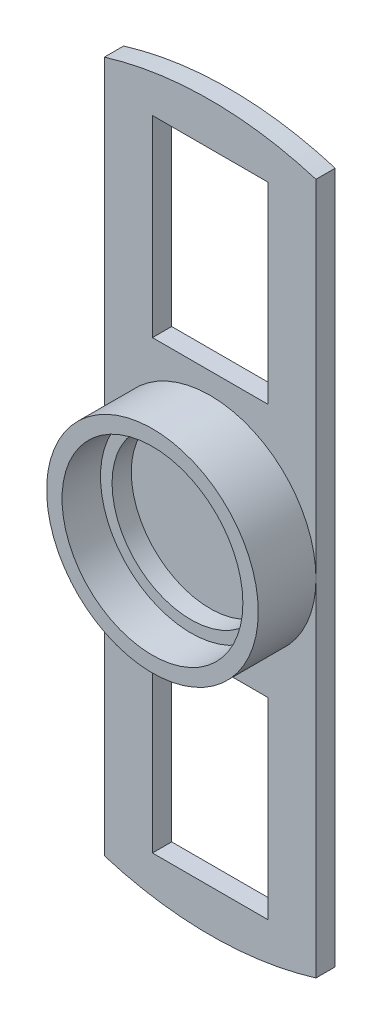
from build123d import *

# Parameters (mm, degrees)
SKETCH1_R           = 27.5
SKETCH1_R_2         = 23.5
BOSS_EXTRUDE1_DEPTH = 10
SKETCH2_R           = 27.5
SKETCH2_R_2         = 20.5
BOSS_EXTRUDE2_DEPTH = 5
BOSS_EXTRUDE3_DEPTH = 5
SKETCH4_W           = 30
SKETCH4_H           = 50
CUT_EXTRUDE1_DEPTH  = 10


with BuildPart() as part:
    # Sketch1 → Boss-Extrude1 (new body)
    with BuildSketch(Plane.XY):
        Circle(SKETCH1_R)
        Circle(SKETCH1_R_2, mode=Mode.SUBTRACT)
    extrude(amount=BOSS_EXTRUDE1_DEPTH)

    # Sketch2 → Boss-Extrude2 (add)
    with BuildSketch(Plane(origin=(0, 0, 0), x_dir=(-1, 0, 0), z_dir=(0, 0, -1))):
        Circle(SKETCH2_R)
        Circle(SKETCH2_R_2, mode=Mode.SUBTRACT)
    extrude(amount=BOSS_EXTRUDE2_DEPTH)

    # Sketch3 → Boss-Extrude3 (add)
    with BuildSketch(Plane(origin=(0, 0, -5), x_dir=(-1, 0, 0), z_dir=(0, 0, -1))):
        with BuildLine():
            Line((-27.5, 89.887429599), (-27.5, -89.887429599))
            ThreePointArc((-27.5, -89.887429599), (0, -94), (27.5, -89.887429599))
            Line((27.5, -89.887429599), (27.5, 89.887429599))
            ThreePointArc((27.5, 89.887429599), (0, 94), (-27.5, 89.887429599))
        make_face()
    extrude(amount=BOSS_EXTRUDE3_DEPTH)

    # Sketch4 → Cut-Extrude1 (cut)
    with BuildSketch(Plane.XY.offset(-5)):
        with Locations((0, -58)):
            Rectangle(SKETCH4_W, SKETCH4_H)
        with Locations((0, 58)):
            Rectangle(SKETCH4_W, SKETCH4_H)
    extrude(amount=-CUT_EXTRUDE1_DEPTH, mode=Mode.SUBTRACT)


solid = part.part
